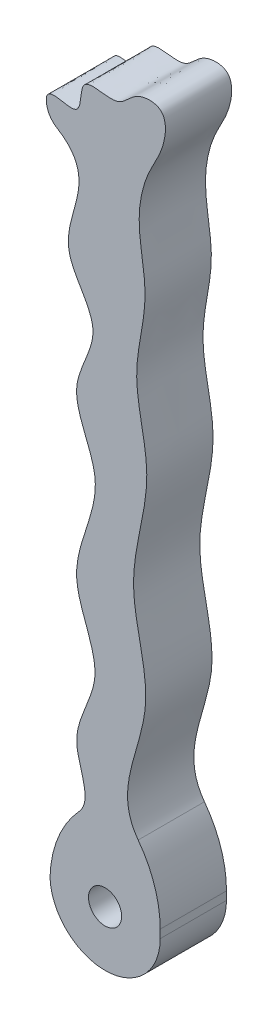
from build123d import *

# Parameters (mm, degrees)
SKETCH1_R           = 1.5
BOSS_EXTRUDE1_DEPTH = 6
FILLET1_R           = 10
FILLET2_R           = 2
CUT_EXTRUDE1_DEPTH  = 6


with BuildPart() as part:
    # Sketch1 → Boss-Extrude1 (new body)
    with BuildSketch(Plane.XY):
        with BuildLine():
            Line((0, 0), (0, -9.98))
            Line((0, -9.98), (9.98, -9.98))
            Line((9.98, -9.98), (9.98, 0))
            add(Edge.make_bspline(
                [(0, 54.250736404), (-1.3001908, 57.732186027), (3.264697289, 54.364229546), (2.426320397, 59.671317952), (6.24965715, 57.931332096), (7.559999273, 60.308317398), (10.808963849, 60.427698471), (10.337139395, 56.901907174), (8.667893464, 54.394927102), (7.624843251, 50.040394793), (9.267984866, 44.554889548), (7.046090887, 37.973638675), (9.84685356, 30.217018819), (6.270285073, 21.673277978), (10.793667439, 11.106885954), (4.474903421, 3.416500301), (9.98, 0)],
                knots=[0, 0, 0, 0, 0.053422047, 0.084053188, 0.123826292, 0.153487584, 0.181182143, 0.220513, 0.254555574, 0.310198036, 0.38825613, 0.476667751, 0.573339812, 0.700293064, 0.81918735, 1, 1, 1, 1], degree=3))
            add(Edge.make_bspline(
                [(0, 54.250736404), (5.084395927, 51.698919308), (-1.040481835, 45.991903649), (5.447322124, 39.887247803), (0.909066537, 34.169036482), (6.005419265, 27.503354662), (0.487031558, 20.054851145), (5.671743487, 12.84454135), (0.403542473, 6.211235786), (5.177057559, 1.35031129), (0, 0)],
                knots=[0, 0, 0, 0, 0.175024795, 0.269809775, 0.365352016, 0.476782251, 0.63395402, 0.755982767, 0.862891176, 1, 1, 1, 1], degree=3))
        make_face()
        with Locations((4.99, -4.99)):
            Circle(SKETCH1_R, mode=Mode.SUBTRACT)
    extrude(amount=BOSS_EXTRUDE1_DEPTH)

    # Fillet1
    fillet1_edges = [part.edges().sort_by_distance(p)[0] for p in [
        (9.98, 0, 3),
        (0, 0, 3),
    ]]
    fillet(fillet1_edges, radius=FILLET1_R)

    # Fillet2
    fillet2_edges = [part.edges().sort_by_distance(p)[0] for p in [
        (0, 54.250736404, 3),
    ]]
    fillet(fillet2_edges, radius=FILLET2_R)

    # Sketch2 → Cut-Extrude1 (cut)
    with BuildSketch(Plane.XY.offset(6)):
        with BuildLine():
            Line((0, -9.98), (4.99, -9.98))
            ThreePointArc((4.99, -9.98), (1.529597004, -8.585234499), (0.003643193, -5.180645734))
            ThreePointArc((0.003643193, -5.180645734), (0.00091084, -5.315587685), (0, -5.450554222))
            Line((0, -5.450554222), (0, -9.98))
        make_face()
        with BuildLine():
            Line((9.98, -9.98), (9.98, -4.99))
            ThreePointArc((9.98, -4.99), (8.518462838, -8.518462838), (4.99, -9.98))
            Line((4.99, -9.98), (9.98, -9.98))
        make_face()
    extrude(amount=-CUT_EXTRUDE1_DEPTH, mode=Mode.SUBTRACT)


solid = part.part
